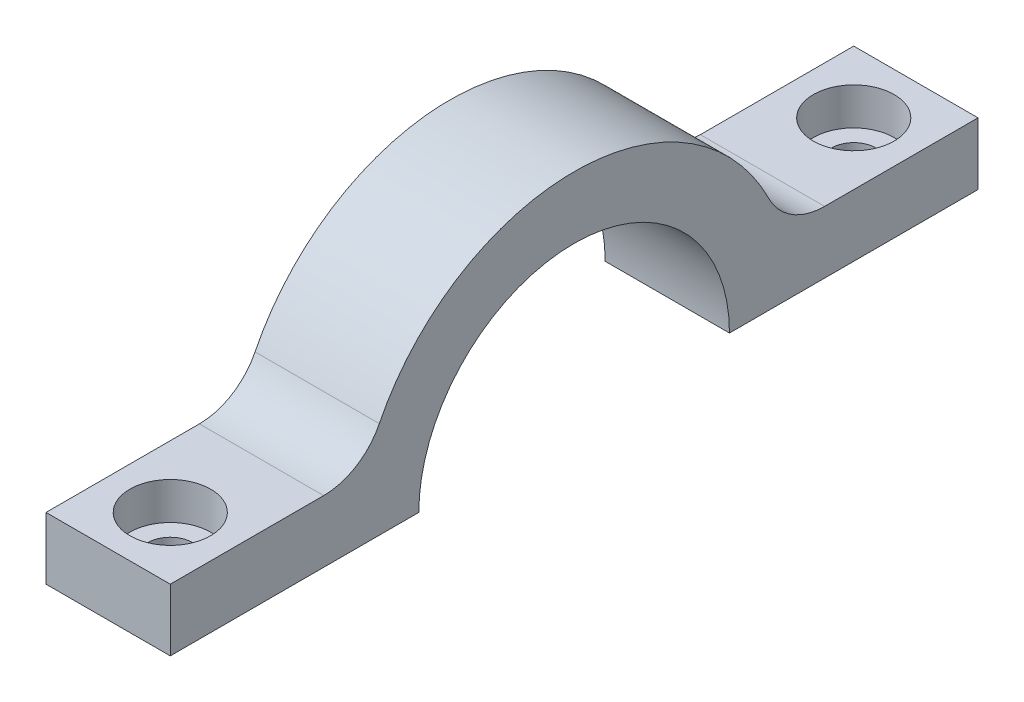
from build123d import *

# Parameters (mm, degrees)
BOSS_EXTRUDE1_DEPTH            = 5
CBORE_FOR_M3_SHCS1_D           = 3.6
CBORE_FOR_M3_SHCS1_DEPTH       = 5
CBORE_FOR_M3_SHCS1_CBORE_D     = 6.5
CBORE_FOR_M3_SHCS1_CBORE_DEPTH = 3
CBORE_FOR_M3_SHCS1_TIP         = 1.081549114
FILLET1_R                      = 5


with BuildPart() as part:
    # Sketch1 → Boss-Extrude1 (new body, symmetric)
    with BuildSketch(Plane(origin=(0, 0, 0), x_dir=(0, 0, -1), z_dir=(1, 0, 0))):
        with BuildLine():
            Line((-32.5, 0), (-12.5, 0))
            ThreePointArc((-12.5, 0), (0, 12.5), (12.5, 0))
            Line((12.5, 0), (32.5, 0))
            Line((32.5, 0), (32.5, 5))
            Line((32.5, 5), (16.770509831, 5))
            ThreePointArc((16.770509831, 5), (0, 17.5), (-16.770509831, 5))
            Line((-16.770509831, 5), (-32.5, 5))
            Line((-32.5, 5), (-32.5, 0))
        make_face()
    extrude(amount=BOSS_EXTRUDE1_DEPTH, both=True)

    # CBORE for M3 SHCS1
    with Locations(Plane(origin=(-41.05, 5, 0), x_dir=(1, 0, 0), z_dir=(0, 1, 0))):
        with Locations((41.05, -27.5), (41.05, 27.5)):
            CounterBoreHole(CBORE_FOR_M3_SHCS1_D / 2, CBORE_FOR_M3_SHCS1_CBORE_D / 2, CBORE_FOR_M3_SHCS1_CBORE_DEPTH, depth=CBORE_FOR_M3_SHCS1_DEPTH)
            with Locations((0, 0, -(CBORE_FOR_M3_SHCS1_DEPTH + CBORE_FOR_M3_SHCS1_TIP / 2))):  # 118° drill point
                Cone(0, CBORE_FOR_M3_SHCS1_D / 2, CBORE_FOR_M3_SHCS1_TIP, mode=Mode.SUBTRACT)

    # Fillet1
    fillet1_edges = [part.edges().sort_by_distance(p)[0] for p in [
        (0, 5, 16.770509831),
        (0, 5, -16.770509831),
    ]]
    fillet(fillet1_edges, radius=FILLET1_R)


solid = part.part
